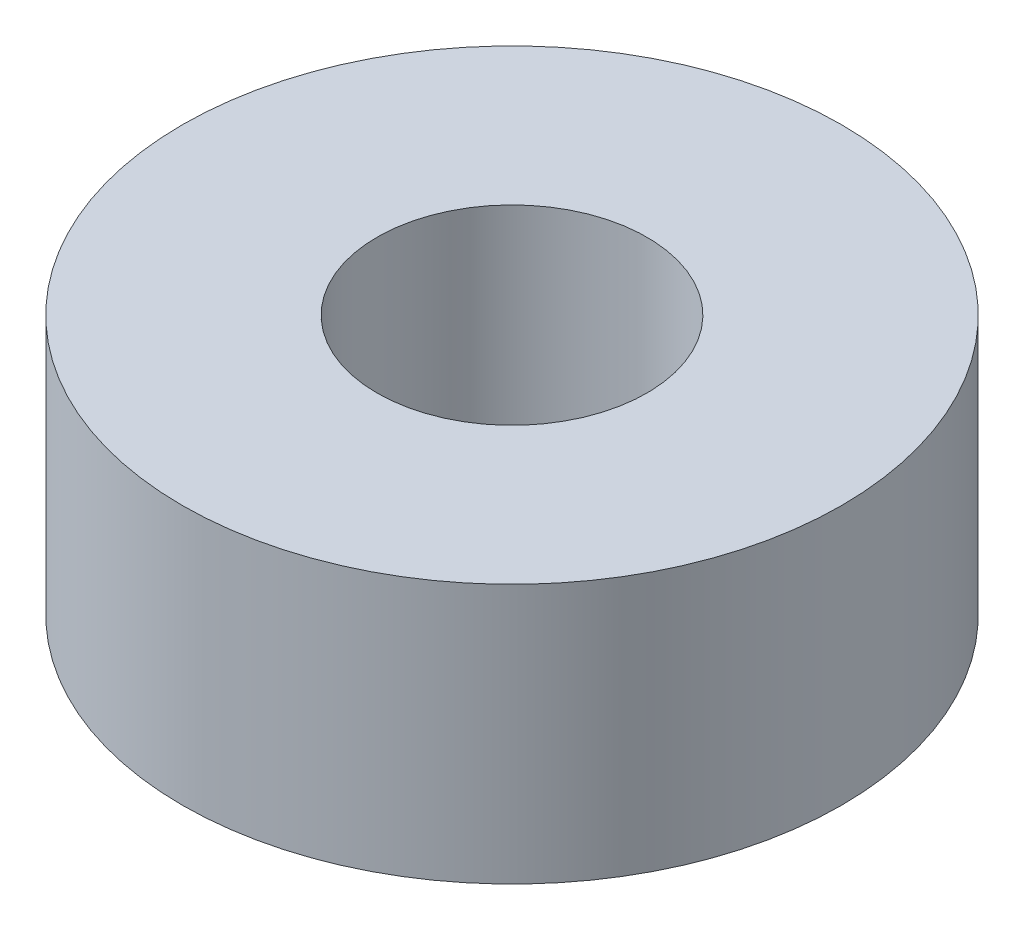
from build123d import *

# Parameters (mm, degrees)
SKETCH1_R           = 8.0645
SKETCH1_R_2         = 3.302
BOSS_EXTRUDE1_DEPTH = 3.175


with BuildPart() as part:
    # Sketch1 → Boss-Extrude1 (new body, symmetric)
    with BuildSketch(Plane(origin=(0, 0, 0), x_dir=(1, 0, 0), z_dir=(0, 1, 0))):
        Circle(SKETCH1_R)
        Circle(SKETCH1_R_2, mode=Mode.SUBTRACT)
    extrude(amount=BOSS_EXTRUDE1_DEPTH, both=True)


solid = part.part
